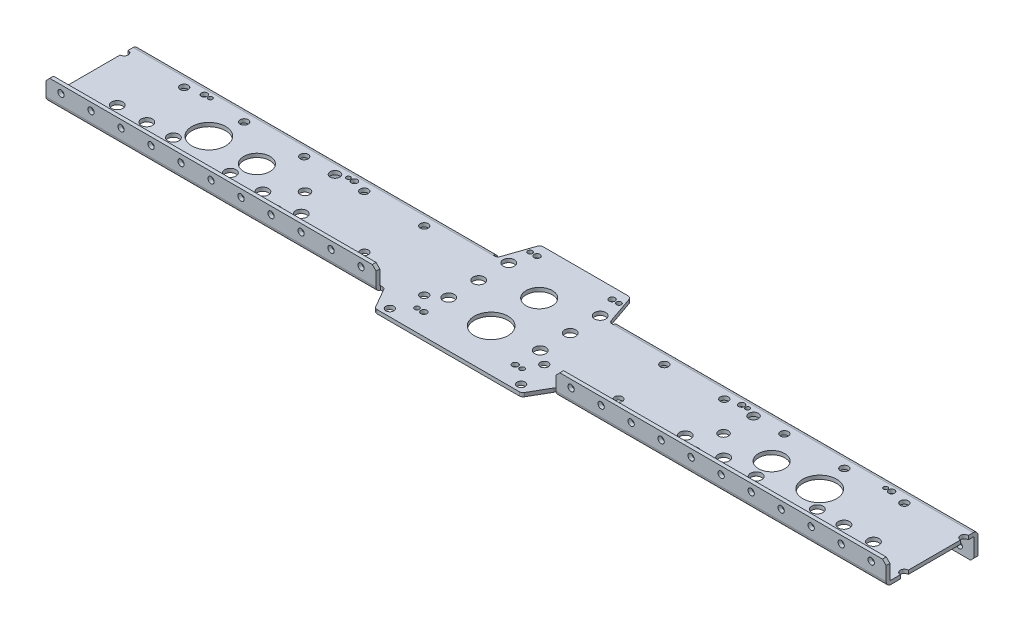
from build123d import *

# Parameters (mm, degrees)
SKETCH1_W                  = 304.8
SKETCH1_H                  = 77.724
BOSS_EXTRUDE1_DEPTH        = 22.225
SKETCH2_W                  = 74.549
SKETCH2_H                  = 19.05
CUT_EXTRUDE1_DEPTH         = 305.8
SKETCH3_W                  = 73.787
SKETCH3_H                  = 3.175
BOSS_EXTRUDE2_DEPTH        = 406.4
SKETCH4_W                  = 304.8
SKETCH4_H                  = 3.175
BOSS_EXTRUDE3_DEPTH        = 3.937
SKETCH5_W                  = 304.8
SKETCH5_H                  = 3.175
BOSS_EXTRUDE4_DEPTH        = 19.05
SKETCH6_W                  = 431.8
SKETCH6_H                  = 3.937
CUT_EXTRUDE2_DEPTH         = 23.225
SKETCH7_W                  = 279.4
SKETCH7_H                  = 3.175
BOSS_EXTRUDE5_DEPTH        = 15.875
SKETCH8_W                  = 279.4
SKETCH8_H                  = 3.175
BOSS_EXTRUDE6_DEPTH        = 3.937
SKETCH9_W                  = 279.4
SKETCH9_H                  = 3.175
BOSS_EXTRUDE7_DEPTH        = 15.875
SKETCH10_W                 = 76.358809824
SKETCH10_H                 = 3.175
BOSS_EXTRUDE8_DEPTH        = 27.432
SKETCH11_W                 = 124.052954744
SKETCH11_H                 = 3.175
BOSS_EXTRUDE9_DEPTH        = 19.05
DRAFT1_ANGLE               = 30
DRAFT2_ANGLE               = 19
M8_CLEARANCE_HOLE1_D       = 9.525
M8_CLEARANCE_HOLE1_DEPTH   = 19.05
M3_5_CLEARANCE_HOLE1_D     = 4.064
M3_5_CLEARANCE_HOLE1_DEPTH = 19.05
HOLE1_D                    = 8.128
HOLE1_DEPTH                = 19.05
M20_CLEARANCE_HOLE1_D      = 22.225
M20_CLEARANCE_HOLE1_DEPTH  = 19.05
M3_CLEARANCE_HOLE1_D       = 3.571875
M3_CLEARANCE_HOLE1_DEPTH   = 19.05
M25_CLEARANCE_HOLE1_D      = 28.575
M25_CLEARANCE_HOLE1_DEPTH  = 19.05
HOLE2_D                    = 5.1054
HOLE2_DEPTH                = 19.05
M6_CLEARANCE_HOLE1_D       = 6.7564
M6_CLEARANCE_HOLE1_DEPTH   = 19.05
M6_CLEARANCE_HOLE2_D       = 6.7564
M6_CLEARANCE_HOLE2_DEPTH   = 22.225
M5_CLEARANCE_HOLE1_D       = 5.334
M5_CLEARANCE_HOLE1_DEPTH   = 101.219
M5_CLEARANCE_HOLE2_D       = 5.334
M5_CLEARANCE_HOLE2_DEPTH   = 26.67
CHAMFER1_SIZE              = 3.175
FILLET1_R                  = 0.762
FILLET2_R                  = 3.175
FILLET3_R                  = 3.937


with BuildPart() as part:
    # Sketch1 → Boss-Extrude1 (new body)
    with BuildSketch(Plane(origin=(0, 3.175, 0), x_dir=(1, 0, 0), z_dir=(0, 1, 0))):
        with Locations((203.2, 34.925)):
            Rectangle(SKETCH1_W, SKETCH1_H)
    extrude(amount=-BOSS_EXTRUDE1_DEPTH)

    # Sketch2 → Cut-Extrude1 (cut, through all)
    with BuildSketch(Plane.ZY.offset(-50.8)):
        with Locations((-33.3375, -9.525)):
            Rectangle(SKETCH2_W, SKETCH2_H)
    extrude(amount=-CUT_EXTRUDE1_DEPTH, mode=Mode.SUBTRACT)

    # Sketch3 → Boss-Extrude2 (add)
    with BuildSketch(Plane(origin=(355.6, 0, 0), x_dir=(0, 0, -1), z_dir=(1, 0, 0))):
        with Locations((32.9565, 1.5875)):
            Rectangle(SKETCH3_W, SKETCH3_H)
    extrude(amount=BOSS_EXTRUDE2_DEPTH)

    # Sketch4 → Boss-Extrude3 (add)
    with BuildSketch(Plane(origin=(0, 0, -69.85), x_dir=(-1, 0, 0), z_dir=(0, 0, -1))):
        with Locations((-609.6, 1.5875)):
            Rectangle(SKETCH4_W, SKETCH4_H)
    extrude(amount=BOSS_EXTRUDE3_DEPTH)

    # Sketch5 → Boss-Extrude4 (add)
    with BuildSketch(Plane.XZ):
        with Locations((609.6, -72.1995)):
            Rectangle(SKETCH5_W, SKETCH5_H)
    extrude(amount=BOSS_EXTRUDE4_DEPTH)

    # Sketch6 → Cut-Extrude2 (cut, through all)
    with BuildSketch(Plane(origin=(0, 3.175, 0), x_dir=(-1, 0, 0), z_dir=(0, 1, 0))):
        with Locations((-266.7, 1.9685)):
            Rectangle(SKETCH6_W, SKETCH6_H)
    extrude(amount=-CUT_EXTRUDE2_DEPTH, mode=Mode.SUBTRACT)

    # Sketch7 → Boss-Extrude5 (add)
    with BuildSketch(Plane(origin=(0, 3.175, 0), x_dir=(-1, 0, 0), z_dir=(0, 1, 0))):
        with Locations((-622.3, 2.3495)):
            Rectangle(SKETCH7_W, SKETCH7_H)
    extrude(amount=BOSS_EXTRUDE5_DEPTH)

    # Sketch8 → Boss-Extrude6 (add)
    with BuildSketch(Plane.XY):
        with Locations((190.5, 1.5875)):
            Rectangle(SKETCH8_W, SKETCH8_H)
    extrude(amount=BOSS_EXTRUDE6_DEPTH)

    # Sketch9 → Boss-Extrude7 (add)
    with BuildSketch(Plane(origin=(0, 3.175, 0), x_dir=(-1, 0, 0), z_dir=(0, 1, 0))):
        with Locations((-190.5, 2.3495)):
            Rectangle(SKETCH9_W, SKETCH9_H)
    extrude(amount=BOSS_EXTRUDE7_DEPTH)

    # Sketch10 → Boss-Extrude8 (add)
    with BuildSketch(Plane(origin=(0, 0, -69.85), x_dir=(-1, 0, 0), z_dir=(0, 0, -1))):
        with Locations((-406.4, 1.5875)):
            Rectangle(SKETCH10_W, SKETCH10_H)
    extrude(amount=BOSS_EXTRUDE8_DEPTH)

    # Sketch11 → Boss-Extrude9 (add)
    with BuildSketch(Plane.XY):
        with Locations((406.4, 1.5875)):
            Rectangle(SKETCH11_W, SKETCH11_H)
    extrude(amount=BOSS_EXTRUDE9_DEPTH)

    # Draft1
    draft1_faces = [part.faces().sort_by_distance(p)[0] for p in [
        (344.373522628, 1.5875, 9.525),
        (468.426477372, 1.5875, 9.525),
    ]]
    draft(draft1_faces, Plane.XY.offset(19.05), DRAFT1_ANGLE)

    # Draft2
    draft2_faces = [part.faces().sort_by_distance(p)[0] for p in [
        (444.579404912, 1.5875, -83.566),
        (368.220595088, 1.5875, -83.566),
    ]]
    draft(draft2_faces, Plane(origin=(0, 0, -97.282), x_dir=(0, -1, 0), z_dir=(0, 0, -1)), DRAFT2_ANGLE)

    # M8 Clearance Hole1
    with Locations(Plane(origin=(0, 0, 0), x_dir=(-1, 0, 0), z_dir=(0, -1, 0))):
        with Locations((-367.67570279, 70.866), (-367.67570279, 20.066), (-445.12429721, 20.066), (-445.12429721, 70.866), (-367.67570279, 45.466), (-445.12429721, 45.466), (-628.947697627, 19.05), (-601.438495912, 19.05), (-568.924874752, 19.05), (-243.875125248, 19.05), (-211.361504088, 19.05), (-183.852302373, 19.05), (-678.944202666, 20.828), (-701.450372003, 20.828), (-726.460886343, 20.828), (-133.855797334, 20.828), (-111.349627997, 20.828), (-86.339113657, 20.828)):
            Hole(M8_CLEARANCE_HOLE1_D / 2, depth=M8_CLEARANCE_HOLE1_DEPTH)

    # M3.5 Clearance Hole1
    with Locations(Plane(origin=(0, 0, 0), x_dir=(-1, 0, 0), z_dir=(0, -1, 0))):
        with Locations((-450.8881, -1.03886), (-361.9119, -1.03886), (-368.808, 87.85352), (-443.992, 87.85352)):
            Hole(M3_5_CLEARANCE_HOLE1_D / 2, depth=M3_5_CLEARANCE_HOLE1_DEPTH)

    # Hole1
    with Locations(Plane(origin=(0, 0, 0), x_dir=(-1, 0, 0), z_dir=(0, -1, 0))):
        with Locations((-583.538437168, 62.23), (-229.261562832, 11.43), (-229.261562832, 62.23), (-229.261562832, 36.83), (-583.538437168, 36.83), (-583.538437168, 11.43)):
            Hole(HOLE1_D / 2, depth=HOLE1_DEPTH)

    # M20 Clearance Hole1
    with Locations(Plane(origin=(0, 0, 0), x_dir=(-1, 0, 0), z_dir=(0, -1, 0))):
        with Locations((-624.254637168, 36.83), (-188.545362832, 36.83), (-406.4, 57.9628)):
            Hole(M20_CLEARANCE_HOLE1_D / 2, depth=M20_CLEARANCE_HOLE1_DEPTH)

    # M3 Clearance Hole1
    with Locations(Plane(origin=(0, 0, 0), x_dir=(-1, 0, 0), z_dir=(0, -1, 0))):
        with Locations((-575.359637168, 8.255), (-237.440362832, 65.405), (-237.440362832, 8.255), (-120.600362832, 8.255), (-120.600362832, 65.405), (-575.359637168, 65.405), (-692.199637168, 65.405), (-692.199637168, 8.255)):
            Hole(M3_CLEARANCE_HOLE1_D / 2, depth=M3_CLEARANCE_HOLE1_DEPTH)

    # M25 Clearance Hole1
    with Locations(Plane(origin=(0, 0, 0), x_dir=(-1, 0, 0), z_dir=(0, -1, 0))):
        with Locations((-664.970837168, 36.83), (-147.829162832, 36.83), (-406.4, 17.272)):
            Hole(M25_CLEARANCE_HOLE1_D / 2, depth=M25_CLEARANCE_HOLE1_DEPTH)

    # Hole2
    with Locations(Plane(origin=(0, 0, 0), x_dir=(-1, 0, 0), z_dir=(0, -1, 0))):
        with Locations((-697.279637168, 8.255), (-697.279637168, 65.405), (-570.279637168, 65.405), (-242.520362832, 65.405), (-242.520362832, 8.255), (-115.520362832, 8.255), (-115.520362832, 65.405), (-367.7539, -1.03886), (-445.0461, -1.03886), (-374.65, 87.85352), (-438.15, 87.85352), (-570.279637168, 8.255)):
            Hole(HOLE2_D / 2, depth=HOLE2_DEPTH)

    # M6 Clearance Hole1
    with Locations(Plane(origin=(0, 0, 0), x_dir=(-1, 0, 0), z_dir=(0, -1, 0))):
        with Locations((-50.8, 62.23), (-762, 62.23), (-461.9625, -12.8905), (-350.8375, -12.8905), (-513.925467617, 17.547282407), (-298.874532383, 17.547282407), (-711.2, 11.43), (-660.4, 62.23), (-660.4, 11.43), (-609.6, 62.23), (-711.2, 62.23), (-152.4, 62.23), (-203.2, 11.43), (-203.2, 62.23), (-254, 11.43), (-101.6, 11.43), (-101.6, 62.23), (-152.4, 11.43), (-254, 62.23), (-304.8, 62.23), (-355.6, 11.43), (-457.2, 11.43), (-609.6, 11.43), (-558.8, 62.23), (-558.8, 11.43), (-508, 62.23)):
            Hole(M6_CLEARANCE_HOLE1_D / 2, depth=M6_CLEARANCE_HOLE1_DEPTH)

    # M6 Clearance Hole2
    with Locations(Plane(origin=(0, 3.175, 0), x_dir=(1, 0, 0), z_dir=(0, 1, 0))):
        with Locations((50.8, 11.43), (762, 11.43)):
            Hole(M6_CLEARANCE_HOLE2_D / 2, depth=M6_CLEARANCE_HOLE2_DEPTH)

    # M5 Clearance Hole1
    with Locations(Plane.XY.offset(3.937)):
        with Locations((495.3, 12.7), (520.7, 12.7), (546.1, 12.7), (571.5, 12.7), (596.9, 12.7), (622.3, 12.7), (647.7, 12.7), (673.1, 12.7), (698.5, 12.7), (723.9, 12.7), (749.3, 12.7), (317.5, 12.7), (292.1, 12.7), (266.7, 12.7), (241.3, 12.7), (215.9, 12.7), (190.5, 12.7), (165.1, 12.7), (139.7, 12.7), (114.3, 12.7), (88.9, 12.7), (63.5, 12.7)):
            Hole(M5_CLEARANCE_HOLE1_D / 2, depth=M5_CLEARANCE_HOLE1_DEPTH)

    # M5 Clearance Hole2
    with Locations(Plane.XY.offset(-70.612)):
        with Locations((342.9, -12.7), (317.5, -12.7), (292.1, -12.7), (266.7, -12.7), (241.3, -12.7), (215.9, -12.7), (190.5, -12.7), (165.1, -12.7), (139.7, -12.7), (114.3, -12.7), (88.9, -12.7), (63.5, -12.7), (469.9, -12.7), (495.3, -12.7), (520.7, -12.7), (546.1, -12.7), (571.5, -12.7), (596.9, -12.7), (622.3, -12.7), (647.7, -12.7), (673.1, -12.7), (698.5, -12.7), (723.9, -12.7), (749.3, -12.7)):
            Hole(M5_CLEARANCE_HOLE2_D / 2, depth=M5_CLEARANCE_HOLE2_DEPTH)

    # Chamfer1
    chamfer1_edges = [part.edges().sort_by_distance(p)[0] for p in [
        (50.8, 19.05, 2.3495),
        (330.2, 19.05, 2.3495),
        (355.6, -19.05, -72.1995),
        (50.8, -19.05, -72.1995),
        (457.2, -19.05, -72.1995),
        (762, -19.05, -72.1995),
        (762, 19.05, 2.3495),
        (482.6, 19.05, 2.3495),
    ]]
    chamfer(chamfer1_edges, length=CHAMFER1_SIZE)

    # Fillet1
    fillet1_edges = [part.edges().sort_by_distance(p)[0] for p in [
        (190.5, 3.175, 0.762),
        (622.3, 3.175, 0.762),
        (203.2, 0, -70.612),
        (609.6, 0, -70.612),
    ]]
    fillet(fillet1_edges, radius=FILLET1_R)

    # Fillet2
    fillet2_edges = [part.edges().sort_by_distance(p)[0] for p in [
        (358.775, 1.5875, -69.85),
        (454.025, 1.5875, -69.85),
        (368.220595088, 1.5875, -97.282),
        (444.579404912, 1.5875, -97.282),
        (479.425, 1.5875, 0),
        (333.375, 1.5875, 0),
        (468.426477372, 1.5875, 19.05),
        (344.373522628, 1.5875, 19.05),
    ]]
    fillet(fillet2_edges, radius=FILLET2_R)

    # Fillet3
    fillet3_edges = [part.edges().sort_by_distance(p)[0] for p in [
        (190.5, 0, 3.937),
        (622.3, 0, 3.937),
        (203.2, 3.175, -73.787),
        (609.6, 3.175, -73.787),
    ]]
    fillet(fillet3_edges, radius=FILLET3_R)


solid = part.part
